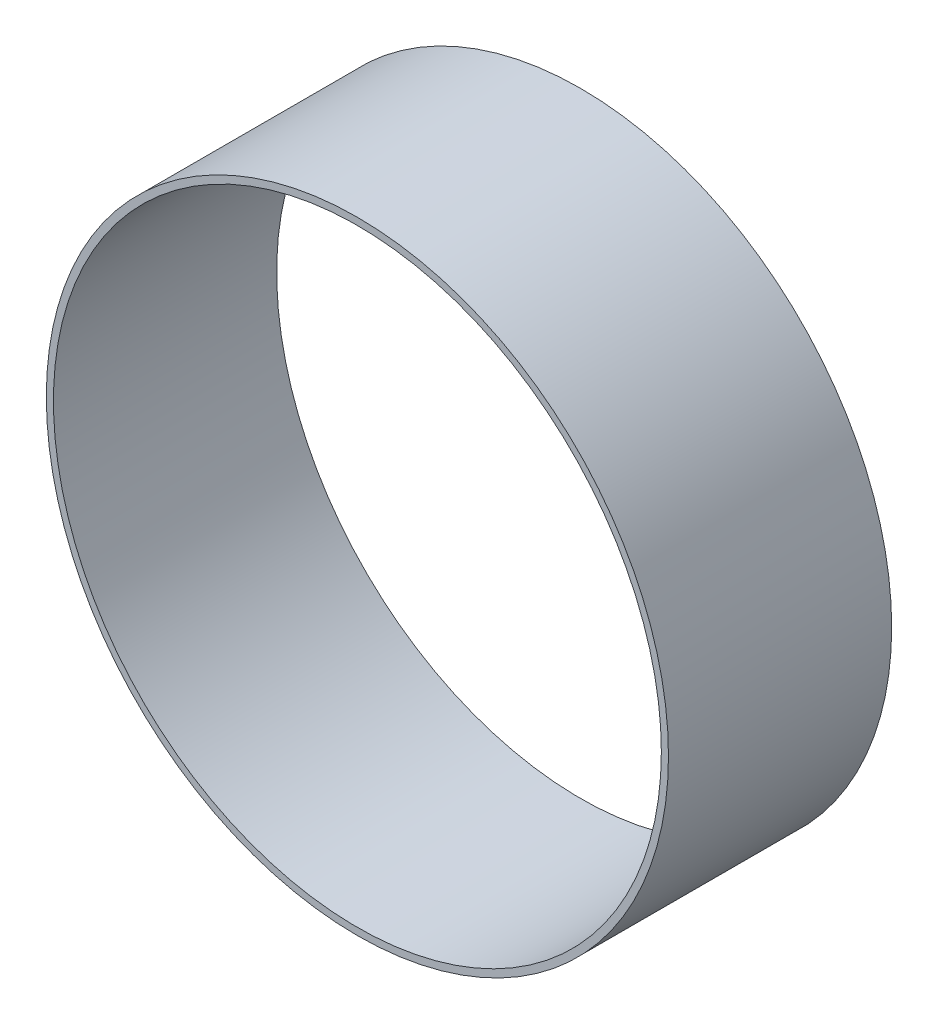
from build123d import *

# Parameters (mm, degrees)
SKETCH1_R           = 207.9625
SKETCH1_R_2         = 203.2
BOSS_EXTRUDE1_DEPTH = 74.6125


with BuildPart() as part:
    # Sketch1 → Boss-Extrude1 (new body, symmetric)
    with BuildSketch(Plane.XY):
        Circle(SKETCH1_R)
        Circle(SKETCH1_R_2, mode=Mode.SUBTRACT)
    extrude(amount=BOSS_EXTRUDE1_DEPTH, both=True)


solid = part.part
